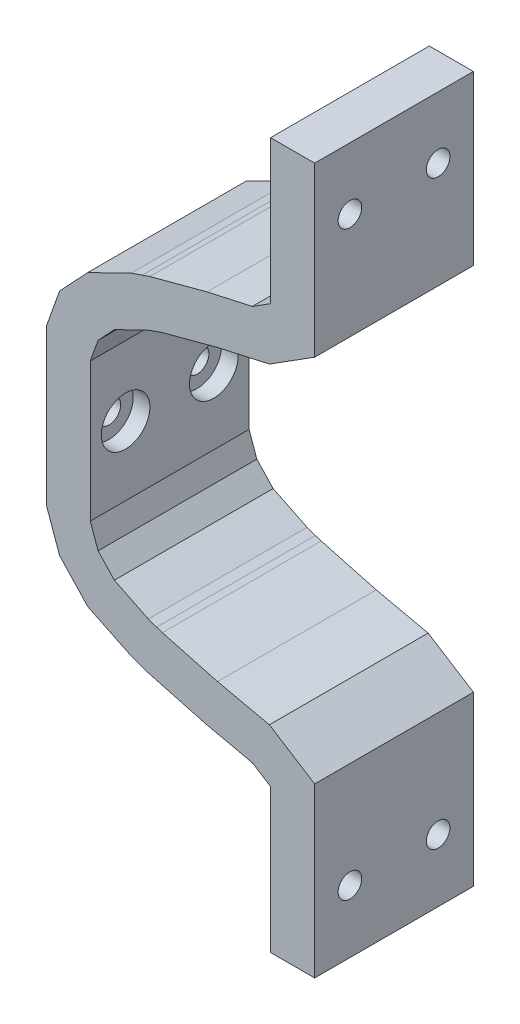
from build123d import *

# Parameters (mm, degrees)
BOSS_EXTRUDE1_DEPTH                              = 22.86
M3_CLEARANCE_HOLE1_D                             = 3.4
CBORE_FOR_M3_PAN_HEAD_MACHINE_SCREW1_D           = 3.4
CBORE_FOR_M3_PAN_HEAD_MACHINE_SCREW1_CBORE_D     = 7
CBORE_FOR_M3_PAN_HEAD_MACHINE_SCREW1_CBORE_DEPTH = 2.4
CUT_EXTRUDE1_DEPTH                               = 2.54


with BuildPart() as part:
    # Model → Boss-Extrude1 (new body)
    with BuildSketch(Plane.XY):
        Polygon((-31.561530074, 5.719031337), (-31.559190751, -16.756549884), (-29.679250105, -22.022082599), (-25.638762019, -26.336998537), (-19.362308162, -29.395591134), (-17.768021154, -29.956483893), (-16.704264105, -30.309706307), (-8.455081931, -32.518568858), (-1.9378711, -33.964713672), (0.686481117, -35.620494321), (0.686481117, -56.318132067), (7.036481117, -56.318132067), (7.036481117, -32.118649881), (0.516193039, -28.004809234), (-6.945353494, -26.349119844), (-14.880902119, -24.224238152), (-15.713611559, -23.947735506), (-16.909625113, -23.526960991), (-21.804194775, -21.141777435), (-24.142511039, -18.644643945), (-25.264614821, -15.501739308), (-25.266693071, 4.465531103), (-24.147092478, 7.603487204), (-21.804194775, 10.105513301), (-16.909625113, 12.490696857), (-15.713611559, 12.911471373), (-14.880902119, 13.187974018), (-6.945353494, 15.312855711), (0.516193039, 16.9685451), (7.036481117, 21.082385748), (7.036481117, 45.281867933), (0.686481117, 45.281867933), (0.686481117, 24.584230187), (-1.9378711, 22.928449538), (-8.455081931, 21.482304725), (-16.704264105, 19.273442173), (-17.768021154, 18.92021976), (-19.362308162, 18.359327), (-25.638762019, 15.300734404), (-29.684302801, 10.980422593), align=None)
    extrude(amount=BOSS_EXTRUDE1_DEPTH)

    # M3 Clearance Hole1 (through all)
    with Locations(Plane.ZY.offset(-0.686481117)):
        with Locations((5.08, 36.391867933), (17.78, 36.391867933), (5.08, -47.308730357), (17.78, -47.308730357)):
            Hole(M3_CLEARANCE_HOLE1_D / 2)

    # CBORE for M3 Pan Head Machine Screw1 (through all)
    with Locations(Plane(origin=(-25.266228013, -0.002629781, 0), x_dir=(0, 0, -1), z_dir=(0.999999995, 0.000104083, 0))):
        with Locations((-5.08, -5.564839092), (-17.78, -5.564839092)):
            CounterBoreHole(CBORE_FOR_M3_PAN_HEAD_MACHINE_SCREW1_D / 2, CBORE_FOR_M3_PAN_HEAD_MACHINE_SCREW1_CBORE_D / 2, CBORE_FOR_M3_PAN_HEAD_MACHINE_SCREW1_CBORE_DEPTH)

    # Sketch5 → Cut-Extrude1 (cut)
    with BuildSketch(Plane.ZY.offset(-0.686481117)):
        Polygon((17.78, -43.642556148), (14.605, -45.475643253), (14.605, -49.141817462), (17.78, -50.974904567), (20.955, -49.141817462), (20.955, -45.475643253), align=None)
        Polygon((5.08, -43.642556148), (1.905, -45.475643253), (1.905, -49.141817462), (5.08, -50.974904567), (8.255, -49.141817462), (8.255, -45.475643253), align=None)
        Polygon((17.78, 40.058042143), (14.605, 38.224955038), (14.605, 34.558780829), (17.78, 32.725693724), (20.955, 34.558780829), (20.955, 38.224955038), align=None)
        Polygon((5.08, 40.058042143), (1.905, 38.224955038), (1.905, 34.558780829), (5.08, 32.725693724), (8.255, 34.558780829), (8.255, 38.224955038), align=None)
    extrude(amount=-CUT_EXTRUDE1_DEPTH, mode=Mode.SUBTRACT)


solid = part.part
